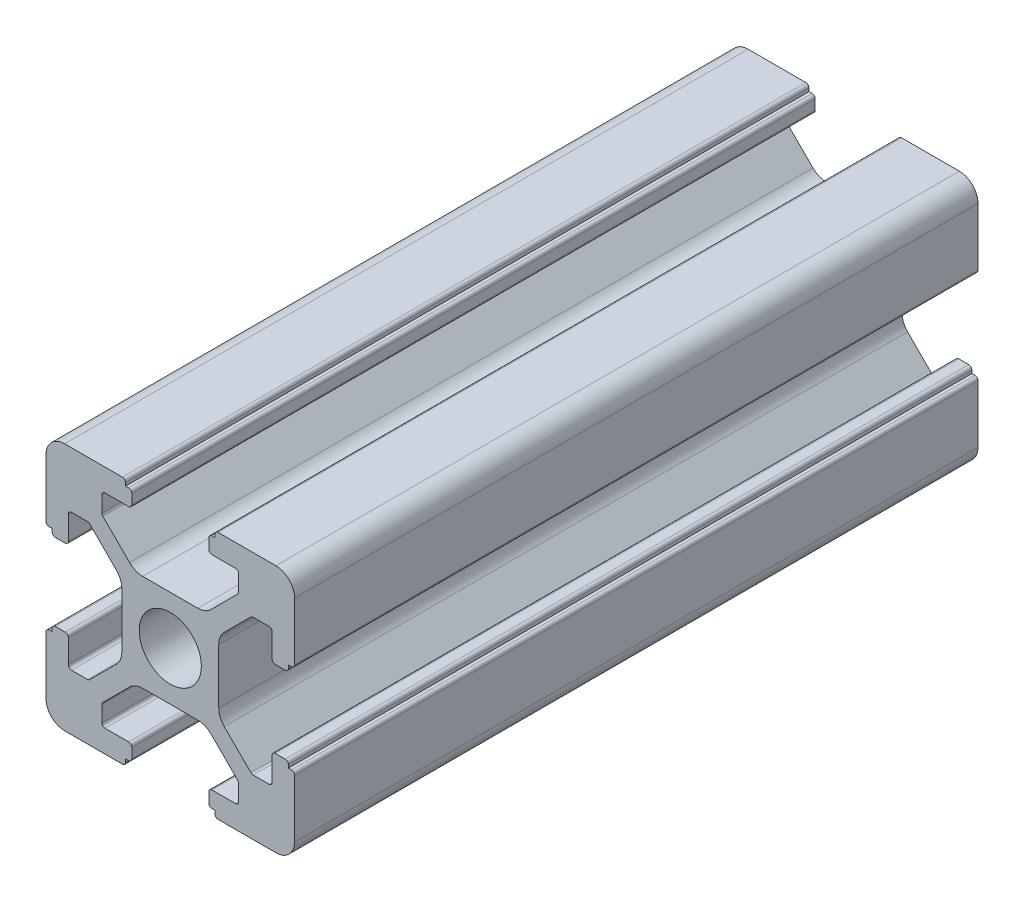
from build123d import *

# Parameters (mm, degrees)
SKETCH_1_R      = 2.5
EXTRUDE_1_DEPTH = 55


with BuildPart() as part:
    # 草图1 → 凸台-拉伸1 (new body)
    with BuildSketch(Plane.XY):
        with BuildLine():
            Line((-8.502261885, -10.002261885), (-3.85, -10.002261885))
            ThreePointArc((-3.85, -10.002261885), (-3.673223305, -9.929038581), (-3.6, -9.752261885))
            Line((-3.6, -9.752261885), (-3.6, -9.502261885))
            Line((-3.6, -9.502261885), (-3.35, -9.502261885))
            ThreePointArc((-3.35, -9.502261885), (-3.173223305, -9.429038581), (-3.1, -9.252261885))
            Line((-3.1, -9.252261885), (-3.1, -8.45))
            ThreePointArc((-3.1, -8.45), (-3.173223305, -8.273223305), (-3.35, -8.2))
            Line((-3.35, -8.2), (-5.25, -8.2))
            ThreePointArc((-5.25, -8.2), (-5.426776695, -8.126776695), (-5.5, -7.95))
            Line((-5.5, -7.95), (-5.5, -6.664213562))
            ThreePointArc((-5.5, -6.664213562), (-5.480969883, -6.568542704), (-5.426776695, -6.487436867))
            Line((-5.426776695, -6.487436867), (-3.278679656, -4.339339828))
            ThreePointArc((-3.278679656, -4.339339828), (-2.792044633, -4.014180701), (-2.218019485, -3.9))
            Line((-2.218019485, -3.9), (2.218019485, -3.9))
            ThreePointArc((2.218019485, -3.9), (2.792044633, -4.014180701), (3.278679656, -4.339339828))
            Line((3.278679656, -4.339339828), (5.426776695, -6.487436867))
            ThreePointArc((5.426776695, -6.487436867), (5.480969883, -6.568542704), (5.5, -6.664213562))
            Line((5.5, -6.664213562), (5.5, -7.95))
            ThreePointArc((5.5, -7.95), (5.426776695, -8.126776695), (5.25, -8.2))
            Line((5.25, -8.2), (3.35, -8.2))
            ThreePointArc((3.35, -8.2), (3.173223305, -8.273223305), (3.1, -8.45))
            Line((3.1, -8.45), (3.1, -9.252261885))
            ThreePointArc((3.1, -9.252261885), (3.173223305, -9.429038581), (3.35, -9.502261885))
            Line((3.35, -9.502261885), (3.6, -9.502261885))
            Line((3.6, -9.502261885), (3.6, -9.752261885))
            ThreePointArc((3.6, -9.752261885), (3.673223305, -9.929038581), (3.85, -10.002261885))
            Line((3.85, -10.002261885), (8.502261885, -10.002261885))
            ThreePointArc((8.502261885, -10.002261885), (9.562922057, -9.562922057), (10.002261885, -8.502261885))
            Line((10.002261885, -8.502261885), (10.002261885, -3.85))
            ThreePointArc((10.002261885, -3.85), (9.929038581, -3.673223305), (9.752261885, -3.6))
            Line((9.752261885, -3.6), (9.502261885, -3.6))
            Line((9.502261885, -3.6), (9.502261885, -3.35))
            ThreePointArc((9.502261885, -3.35), (9.429038581, -3.173223305), (9.252261885, -3.1))
            Line((9.252261885, -3.1), (8.45, -3.1))
            ThreePointArc((8.45, -3.1), (8.273223305, -3.173223305), (8.2, -3.35))
            Line((8.2, -3.35), (8.2, -5.25))
            ThreePointArc((8.2, -5.25), (8.126776695, -5.426776695), (7.95, -5.5))
            Line((7.95, -5.5), (6.664213562, -5.5))
            ThreePointArc((6.664213562, -5.5), (6.568542704, -5.480969883), (6.487436867, -5.426776695))
            Line((6.487436867, -5.426776695), (4.339339828, -3.278679656))
            ThreePointArc((4.339339828, -3.278679656), (4.014180701, -2.792044633), (3.9, -2.218019485))
            Line((3.9, -2.218019485), (3.9, 2.218019485))
            ThreePointArc((3.9, 2.218019485), (4.014180701, 2.792044633), (4.339339828, 3.278679656))
            Line((4.339339828, 3.278679656), (6.487436867, 5.426776695))
            ThreePointArc((6.487436867, 5.426776695), (6.568542704, 5.480969883), (6.664213562, 5.5))
            Line((6.664213562, 5.5), (7.95, 5.5))
            ThreePointArc((7.95, 5.5), (8.126776695, 5.426776695), (8.2, 5.25))
            Line((8.2, 5.25), (8.2, 3.35))
            ThreePointArc((8.2, 3.35), (8.273223305, 3.173223305), (8.45, 3.1))
            Line((8.45, 3.1), (9.252261885, 3.1))
            ThreePointArc((9.252261885, 3.1), (9.429038581, 3.173223305), (9.502261885, 3.35))
            Line((9.502261885, 3.35), (9.502261885, 3.6))
            Line((9.502261885, 3.6), (9.752261885, 3.6))
            ThreePointArc((9.752261885, 3.6), (9.929038581, 3.673223305), (10.002261885, 3.85))
            Line((10.002261885, 3.85), (10.002261885, 8.502261885))
            ThreePointArc((10.002261885, 8.502261885), (9.562922057, 9.562922057), (8.502261885, 10.002261885))
            Line((8.502261885, 10.002261885), (3.85, 10.002261885))
            ThreePointArc((3.85, 10.002261885), (3.673223305, 9.929038581), (3.6, 9.752261885))
            Line((3.6, 9.752261885), (3.6, 9.502261885))
            Line((3.6, 9.502261885), (3.35, 9.502261885))
            ThreePointArc((3.35, 9.502261885), (3.173223305, 9.429038581), (3.1, 9.252261885))
            Line((3.1, 9.252261885), (3.1, 8.45))
            ThreePointArc((3.1, 8.45), (3.173223305, 8.273223305), (3.35, 8.2))
            Line((3.35, 8.2), (5.25, 8.2))
            ThreePointArc((5.25, 8.2), (5.426776695, 8.126776695), (5.5, 7.95))
            Line((5.5, 7.95), (5.5, 6.664213562))
            ThreePointArc((5.5, 6.664213562), (5.480969883, 6.568542704), (5.426776695, 6.487436867))
            Line((5.426776695, 6.487436867), (3.278679656, 4.339339828))
            ThreePointArc((3.278679656, 4.339339828), (2.792044633, 4.014180701), (2.218019485, 3.9))
            Line((2.218019485, 3.9), (-2.218019485, 3.9))
            ThreePointArc((-2.218019485, 3.9), (-2.792044633, 4.014180701), (-3.278679656, 4.339339828))
            Line((-3.278679656, 4.339339828), (-5.426776695, 6.487436867))
            ThreePointArc((-5.426776695, 6.487436867), (-5.480969883, 6.568542704), (-5.5, 6.664213562))
            Line((-5.5, 6.664213562), (-5.5, 7.95))
            ThreePointArc((-5.5, 7.95), (-5.426776695, 8.126776695), (-5.25, 8.2))
            Line((-5.25, 8.2), (-3.35, 8.2))
            ThreePointArc((-3.35, 8.2), (-3.173223305, 8.273223305), (-3.1, 8.45))
            Line((-3.1, 8.45), (-3.1, 9.252261885))
            ThreePointArc((-3.1, 9.252261885), (-3.173223305, 9.429038581), (-3.35, 9.502261885))
            Line((-3.35, 9.502261885), (-3.6, 9.502261885))
            Line((-3.6, 9.502261885), (-3.6, 9.752261885))
            ThreePointArc((-3.6, 9.752261885), (-3.673223305, 9.929038581), (-3.85, 10.002261885))
            Line((-3.85, 10.002261885), (-8.502261885, 10.002261885))
            ThreePointArc((-8.502261885, 10.002261885), (-9.562922057, 9.562922057), (-10.002261885, 8.502261885))
            Line((-10.002261885, 8.502261885), (-10.002261885, 3.85))
            ThreePointArc((-10.002261885, 3.85), (-9.929038581, 3.673223305), (-9.752261885, 3.6))
            Line((-9.752261885, 3.6), (-9.502261885, 3.6))
            Line((-9.502261885, 3.6), (-9.502261885, 3.35))
            ThreePointArc((-9.502261885, 3.35), (-9.429038581, 3.173223305), (-9.252261885, 3.1))
            Line((-9.252261885, 3.1), (-8.45, 3.1))
            ThreePointArc((-8.45, 3.1), (-8.273223305, 3.173223305), (-8.2, 3.35))
            Line((-8.2, 3.35), (-8.2, 5.25))
            ThreePointArc((-8.2, 5.25), (-8.126776695, 5.426776695), (-7.95, 5.5))
            Line((-7.95, 5.5), (-6.664213562, 5.5))
            ThreePointArc((-6.664213562, 5.5), (-6.568542704, 5.480969883), (-6.487436867, 5.426776695))
            Line((-6.487436867, 5.426776695), (-4.339339828, 3.278679656))
            ThreePointArc((-4.339339828, 3.278679656), (-4.014180701, 2.792044633), (-3.9, 2.218019485))
            Line((-3.9, 2.218019485), (-3.9, -2.218019485))
            ThreePointArc((-3.9, -2.218019485), (-4.014180701, -2.792044633), (-4.339339828, -3.278679656))
            Line((-4.339339828, -3.278679656), (-6.487436867, -5.426776695))
            ThreePointArc((-6.487436867, -5.426776695), (-6.568542704, -5.480969883), (-6.664213562, -5.5))
            Line((-6.664213562, -5.5), (-7.95, -5.5))
            ThreePointArc((-7.95, -5.5), (-8.126776695, -5.426776695), (-8.2, -5.25))
            Line((-8.2, -5.25), (-8.2, -3.35))
            ThreePointArc((-8.2, -3.35), (-8.273223305, -3.173223305), (-8.45, -3.1))
            Line((-8.45, -3.1), (-9.252261885, -3.1))
            ThreePointArc((-9.252261885, -3.1), (-9.429038581, -3.173223305), (-9.502261885, -3.35))
            Line((-9.502261885, -3.35), (-9.502261885, -3.6))
            Line((-9.502261885, -3.6), (-9.752261885, -3.6))
            ThreePointArc((-9.752261885, -3.6), (-9.929038581, -3.673223305), (-10.002261885, -3.85))
            Line((-10.002261885, -3.85), (-10.002261885, -8.502261885))
            ThreePointArc((-10.002261885, -8.502261885), (-9.562922057, -9.562922057), (-8.502261885, -10.002261885))
        make_face()
        Circle(SKETCH_1_R, mode=Mode.SUBTRACT)
    extrude(amount=EXTRUDE_1_DEPTH)


solid = part.part
